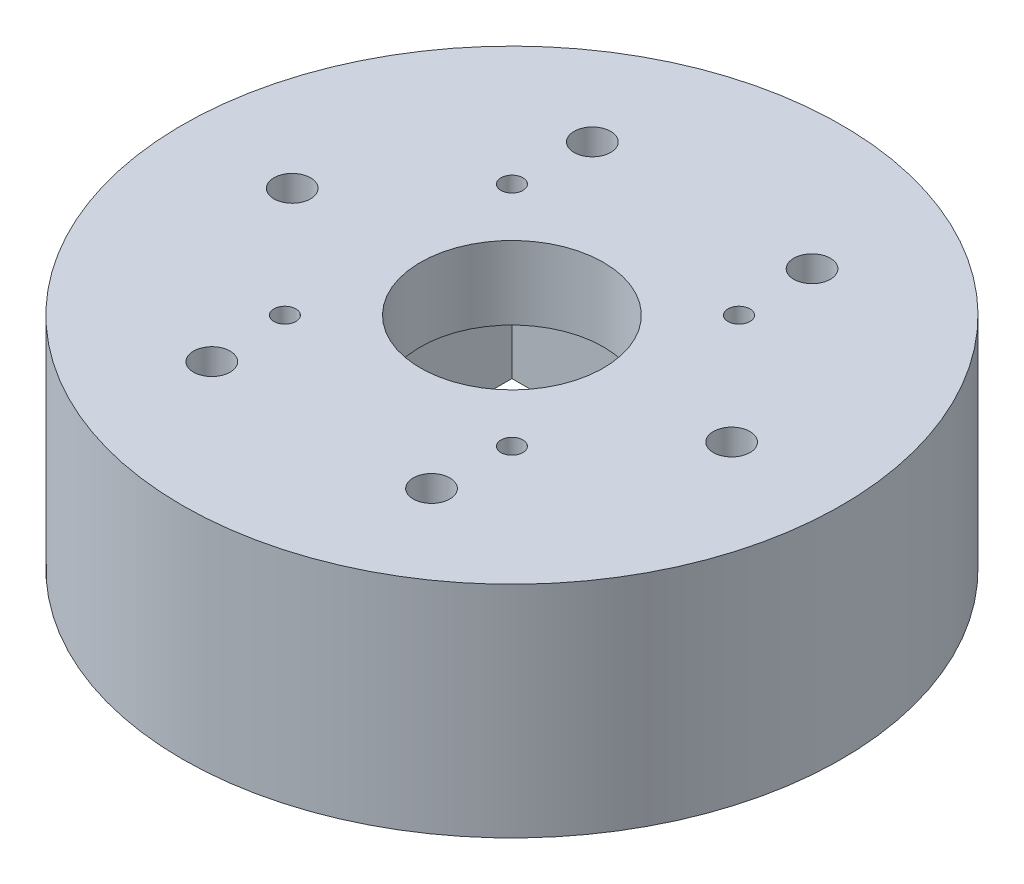
from build123d import *

# Parameters (mm, degrees)
SKETCH1_R           = 45
BOSS_EXTRUDE1_DEPTH = 30
SKETCH2_R           = 4
CUT_EXTRUDE1_DEPTH  = 20
SKETCH4_R           = 2.5
CUT_EXTRUDE2_DEPTH  = 30
SKETCH5_W           = 45
SKETCH5_H           = 45
CUT_EXTRUDE3_DEPTH  = 20
SKETCH6_R           = 12.5
CUT_EXTRUDE4_DEPTH  = 10


with BuildPart() as part:
    # Sketch1 → Boss-Extrude1 (new body)
    with BuildSketch(Plane(origin=(0, 0, 0), x_dir=(1, 0, 0), z_dir=(0, 1, 0))):
        Circle(SKETCH1_R)
    extrude(amount=BOSS_EXTRUDE1_DEPTH)

    # Sketch2 → Cut-Extrude1 (cut)
    with BuildSketch(Plane.XZ):
        with Locations((0, 32.5)):
            Circle(SKETCH2_R)
        with Locations((0, -32.5)):
            Circle(SKETCH2_R)
    extrude(amount=-CUT_EXTRUDE1_DEPTH, mode=Mode.SUBTRACT)

    # Sketch4 → Cut-Extrude2 (cut)
    with BuildSketch(Plane(origin=(0, 0, 0), x_dir=(-1, 0, 0), z_dir=(0, -1, 0))):
        with Locations((-30, 0)):
            Circle(SKETCH4_R)
        with Locations((-15, 25.980762114)):
            Circle(SKETCH4_R)
        with Locations((15, 25.980762114)):
            Circle(SKETCH4_R)
        with Locations((30, 0)):
            Circle(SKETCH4_R)
        with Locations((15, -25.980762114)):
            Circle(SKETCH4_R)
        with Locations((-15, -25.980762114)):
            Circle(SKETCH4_R)
    extrude(amount=-CUT_EXTRUDE2_DEPTH, mode=Mode.SUBTRACT)

    # Sketch5 → Cut-Extrude3 (cut)
    with BuildSketch(Plane(origin=(0, 0, 0), x_dir=(-1, 0, 0), z_dir=(0, -1, 0))):
        Rectangle(SKETCH5_W, SKETCH5_H)
    extrude(amount=-CUT_EXTRUDE3_DEPTH, mode=Mode.SUBTRACT)

    # Sketch6 → Cut-Extrude4 (cut)
    with BuildSketch(Plane.XZ.offset(-20)):
        with BuildLine():
            Line((-15.5, 14), (-15.5, 15.5))
            Line((-15.5, 15.5), (-14, 15.5))
            ThreePointArc((-14, 15.5), (-16.560660172, 16.560660172), (-15.5, 14))
        make_face()
        with BuildLine():
            Line((-14, 15.5), (-15.5, 15.5))
            Line((-15.5, 15.5), (-15.5, 14))
            ThreePointArc((-15.5, 14), (-14.439339828, 14.439339828), (-14, 15.5))
        make_face()
        with BuildLine():
            ThreePointArc((17, 15.5), (15.5, 17), (14, 15.5))
            Line((14, 15.5), (15.5, 15.5))
            Line((15.5, 15.5), (15.5, 14))
            ThreePointArc((15.5, 14), (16.560660172, 14.439339828), (17, 15.5))
        make_face()
        with BuildLine():
            Line((15.5, 15.5), (14, 15.5))
            ThreePointArc((14, 15.5), (14.439339828, 14.439339828), (15.5, 14))
            Line((15.5, 14), (15.5, 15.5))
        make_face()
        Circle(SKETCH6_R)
        with BuildLine():
            ThreePointArc((17, -15.5), (16.560660172, -14.439339828), (15.5, -14))
            Line((15.5, -14), (15.5, -15.5))
            Line((15.5, -15.5), (14, -15.5))
            ThreePointArc((14, -15.5), (15.5, -17), (17, -15.5))
        make_face()
        with BuildLine():
            Line((15.5, -15.5), (15.5, -14))
            ThreePointArc((15.5, -14), (14.439339828, -14.439339828), (14, -15.5))
            Line((14, -15.5), (15.5, -15.5))
        make_face()
        with BuildLine():
            ThreePointArc((-14, -15.5), (-14.439339828, -14.439339828), (-15.5, -14))
            Line((-15.5, -14), (-15.5, -15.5))
            Line((-15.5, -15.5), (-14, -15.5))
        make_face()
        with BuildLine():
            Line((-15.5, -15.5), (-15.5, -14))
            ThreePointArc((-15.5, -14), (-16.560660172, -16.560660172), (-14, -15.5))
            Line((-14, -15.5), (-15.5, -15.5))
        make_face()
    extrude(amount=-CUT_EXTRUDE4_DEPTH, mode=Mode.SUBTRACT)


solid = part.part
